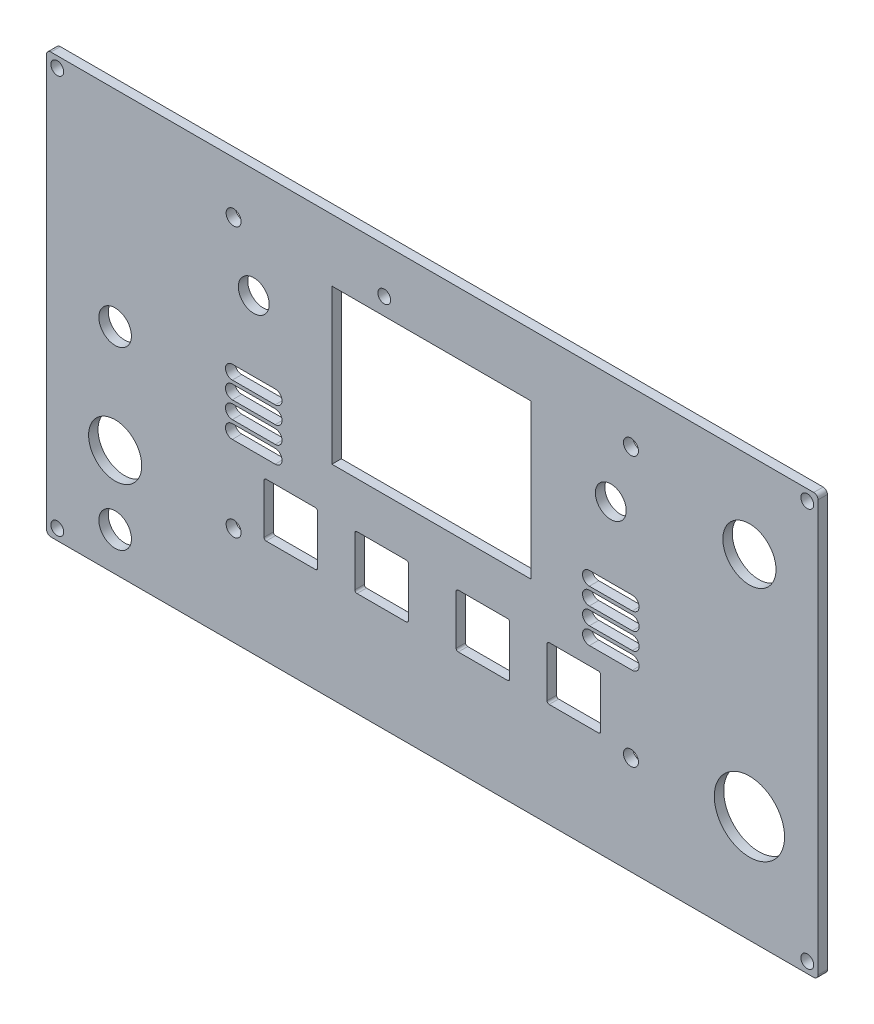
from build123d import *

# Parameters (mm, degrees)
SKETCH_1_W      = 180
SKETCH_1_H      = 98
SKETCH_1_R      = 6.2
SKETCH_1_R_2    = 8.2
SKETCH_1_R_3    = 1.5
SKETCH_1_R_4    = 1.75
SKETCH_1_R_5    = 3.6
SKETCH_1_R_6    = 3.8
SKETCH_1_W_2    = 12.5
SKETCH_1_H_2    = 12.5
SKETCH_1_W_3    = 46.5
SKETCH_1_H_3    = 36
EXTRUDE_1_DEPTH = 2.2
FILLET_1_R      = 1
FILLET_2_R      = 0.5


with BuildPart() as part:
    # Эскиз1 → Бобышка-Вытянуть1 (new body)
    with BuildSketch(Plane.XY):
        with Locations((49.911, 29.5)):
            Rectangle(SKETCH_1_W, SKETCH_1_H)
        with Locations((-24.089, 5.5)):
            Circle(SKETCH_1_R, mode=Mode.SUBTRACT)
        with Locations((123.911, 58.5)):
            Circle(SKETCH_1_R, mode=Mode.SUBTRACT)
        with Locations((123.911, 5.5)):
            Circle(SKETCH_1_R_2, mode=Mode.SUBTRACT)
        with Locations((-37.589, 76)):
            Circle(SKETCH_1_R_3, mode=Mode.SUBTRACT)
        with Locations((137.411, 76)):
            Circle(SKETCH_1_R_3, mode=Mode.SUBTRACT)
        with Locations((137.411, -17)):
            Circle(SKETCH_1_R_3, mode=Mode.SUBTRACT)
        with Locations((-37.589, -17)):
            Circle(SKETCH_1_R_3, mode=Mode.SUBTRACT)
        with Locations((3.556, 3.556)):
            Circle(SKETCH_1_R_4, mode=Mode.SUBTRACT)
        with Locations((3.556, 66.421)):
            Circle(SKETCH_1_R_4, mode=Mode.SUBTRACT)
        with Locations((96.266, 66.421)):
            Circle(SKETCH_1_R_4, mode=Mode.SUBTRACT)
        with Locations((96.266, 3.556)):
            Circle(SKETCH_1_R_4, mode=Mode.SUBTRACT)
        with Locations((8.255, 52.959)):
            Circle(SKETCH_1_R_5, mode=Mode.SUBTRACT)
        with Locations((91.567, 52.959)):
            Circle(SKETCH_1_R_5, mode=Mode.SUBTRACT)
        with Locations((-24.089, 30.5)):
            Circle(SKETCH_1_R_6, mode=Mode.SUBTRACT)
        with Locations((-24.089, -10.5)):
            Circle(SKETCH_1_R_6, mode=Mode.SUBTRACT)
        with Locations((38.7, 68)):
            Circle(SKETCH_1_R_3, mode=Mode.SUBTRACT)
        with Locations((16.891, 11.049)):
            Rectangle(SKETCH_1_W_2, SKETCH_1_H_2, mode=Mode.SUBTRACT)
        with Locations((38.1, 11.049)):
            Rectangle(SKETCH_1_W_2, SKETCH_1_H_2, mode=Mode.SUBTRACT)
        with Locations((61.722, 11.049)):
            Rectangle(SKETCH_1_W_2, SKETCH_1_H_2, mode=Mode.SUBTRACT)
        with Locations((82.931, 11.049)):
            Rectangle(SKETCH_1_W_2, SKETCH_1_H_2, mode=Mode.SUBTRACT)
        with Locations((49.75, 46)):
            Rectangle(SKETCH_1_W_3, SKETCH_1_H_3, mode=Mode.SUBTRACT)
        with BuildLine():
            Line((3.255, 36.5885), (13.255, 36.5885))
            ThreePointArc((13.255, 36.5885), (14.855, 34.9885), (13.255, 33.3885))
            Line((13.255, 33.3885), (3.255, 33.3885))
            ThreePointArc((3.255, 33.3885), (1.655, 34.9885), (3.255, 36.5885))
        make_face(mode=Mode.SUBTRACT)
        with BuildLine():
            Line((96.567, 33.3885), (86.567, 33.3885))
            ThreePointArc((86.567, 33.3885), (84.967, 34.9885), (86.567, 36.5885))
            Line((86.567, 36.5885), (96.567, 36.5885))
            ThreePointArc((96.567, 36.5885), (98.167, 34.9885), (96.567, 33.3885))
        make_face(mode=Mode.SUBTRACT)
        with BuildLine():
            Line((3.255, 32.5885), (13.255, 32.5885))
            ThreePointArc((13.255, 32.5885), (14.855, 30.9885), (13.255, 29.3885))
            Line((13.255, 29.3885), (3.255, 29.3885))
            ThreePointArc((3.255, 29.3885), (1.655, 30.9885), (3.255, 32.5885))
        make_face(mode=Mode.SUBTRACT)
        with BuildLine():
            Line((96.567, 29.3885), (86.567, 29.3885))
            ThreePointArc((86.567, 29.3885), (84.967, 30.9885), (86.567, 32.5885))
            Line((86.567, 32.5885), (96.567, 32.5885))
            ThreePointArc((96.567, 32.5885), (98.167, 30.9885), (96.567, 29.3885))
        make_face(mode=Mode.SUBTRACT)
        with BuildLine():
            Line((3.255, 28.5885), (13.255, 28.5885))
            ThreePointArc((13.255, 28.5885), (14.855, 26.9885), (13.255, 25.3885))
            Line((13.255, 25.3885), (3.255, 25.3885))
            ThreePointArc((3.255, 25.3885), (1.655, 26.9885), (3.255, 28.5885))
        make_face(mode=Mode.SUBTRACT)
        with BuildLine():
            Line((96.567, 25.3885), (86.567, 25.3885))
            ThreePointArc((86.567, 25.3885), (84.967, 26.9885), (86.567, 28.5885))
            Line((86.567, 28.5885), (96.567, 28.5885))
            ThreePointArc((96.567, 28.5885), (98.167, 26.9885), (96.567, 25.3885))
        make_face(mode=Mode.SUBTRACT)
        with BuildLine():
            Line((3.255, 24.5885), (13.255, 24.5885))
            ThreePointArc((13.255, 24.5885), (14.855, 22.9885), (13.255, 21.3885))
            Line((13.255, 21.3885), (3.255, 21.3885))
            ThreePointArc((3.255, 21.3885), (1.655, 22.9885), (3.255, 24.5885))
        make_face(mode=Mode.SUBTRACT)
        with BuildLine():
            Line((96.567, 21.3885), (86.567, 21.3885))
            ThreePointArc((86.567, 21.3885), (84.967, 22.9885), (86.567, 24.5885))
            Line((86.567, 24.5885), (96.567, 24.5885))
            ThreePointArc((96.567, 24.5885), (98.167, 22.9885), (96.567, 21.3885))
        make_face(mode=Mode.SUBTRACT)
    extrude(amount=EXTRUDE_1_DEPTH)

    # Скругление1
    fillet_1_edges = [part.edges().sort_by_distance(p)[0] for p in [
        (139.911, -19.5, 1.1),
        (-40.089, -19.5, 1.1),
        (-40.089, 78.5, 1.1),
        (139.911, 78.5, 1.1),
    ]]
    fillet(fillet_1_edges, radius=FILLET_1_R)

    # Скругление2
    fillet_2_edges = [part.edges().sort_by_distance(p)[0] for p in [
        (89.181, 4.799, 1.1),
        (89.181, 17.299, 1.1),
        (76.681, 17.299, 1.1),
        (76.681, 4.799, 1.1),
        (23.141, 4.799, 1.1),
        (23.141, 17.299, 1.1),
        (10.641, 17.299, 1.1),
        (10.641, 4.799, 1.1),
        (44.35, 4.799, 1.1),
        (44.35, 17.299, 1.1),
        (31.85, 17.299, 1.1),
        (31.85, 4.799, 1.1),
        (67.972, 4.799, 1.1),
        (67.972, 17.299, 1.1),
        (55.472, 17.299, 1.1),
        (55.472, 4.799, 1.1),
    ]]
    fillet(fillet_2_edges, radius=FILLET_2_R)


solid = part.part
